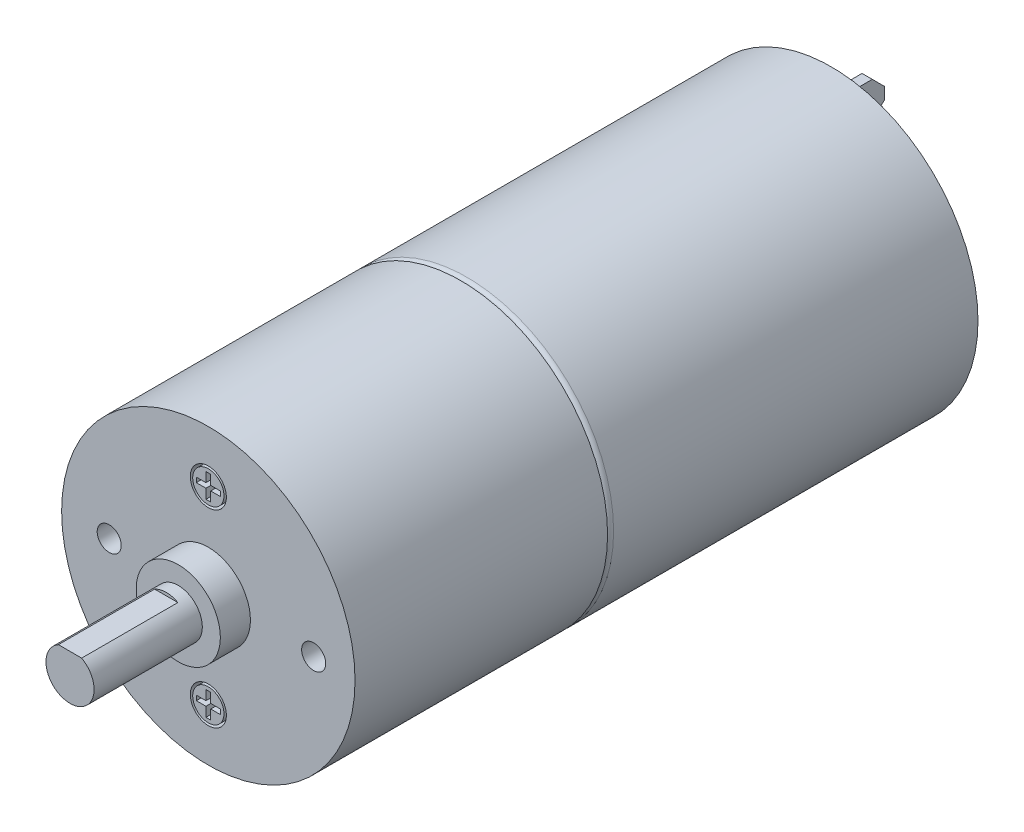
from build123d import *

# Parameters (mm, degrees)
IZIM1_R                     = 12.2
Y_KSEKLIK_EKSTR_ZYON1_DEPTH = 30.8
RADYUS1_R                   = 0.5
IZIM2_R                     = 12.2
Y_KSEKLIK_EKSTR_ZYON2_DEPTH = 21
IZIM3_R                     = 3.5
Y_KSEKLIK_EKSTR_ZYON3_DEPTH = 2.5
IZIM4_R                     = 2
Y_KSEKLIK_EKSTR_ZYON4_DEPTH = 9
IZIM5_R                     = 1
KES_EKSTR_ZYON1_DEPTH       = 10
IZIM6_R                     = 1.5
IZIM6_R_2                   = 1.3
KES_EKSTR_ZYON2_DEPTH       = 1
KES_EKSTR_ZYON3_DEPTH       = 8
IZIM9_R                     = 3.25
Y_KSEKLIK_EKSTR_ZYON5_DEPTH = 1
IZIM10_R                    = 0.75
Y_KSEKLIK_EKSTR_ZYON6_DEPTH = 5
IZIM11_W                    = 0.852537123
IZIM11_H                    = 3
Y_KSEKLIK_EKSTR_ZYON7_DEPTH = 4
IZIM12_R                    = 0.75
KES_EKSTR_ZYON4_DEPTH       = 4
PAH1_SIZE                   = 1


with BuildPart() as part:
    # izim1 → Y_kseklik-Ekstr_zyon1 (new body)
    with BuildSketch(Plane.XY):
        with Locations(Location((-41.143471688, 10.161406423, 0), (0, 0, 180))):
            Circle(IZIM1_R)
    extrude(amount=Y_KSEKLIK_EKSTR_ZYON1_DEPTH)

    # Radyus1
    radyus1_edges = [part.edges().sort_by_distance(p)[0] for p in [
        (-28.943471688, 10.161406423, 30.8),
    ]]
    fillet(radyus1_edges, radius=RADYUS1_R)

    # izim2 → Y_kseklik-Ekstr_zyon2 (add)
    with BuildSketch(Plane.XY.offset(30.8)):
        with Locations(Location((-41.143471688, 10.161406423, 0), (0, 0, 180))):
            Circle(IZIM2_R)
    extrude(amount=Y_KSEKLIK_EKSTR_ZYON2_DEPTH)

    # izim3 → Y_kseklik-Ekstr_zyon3 (add)
    with BuildSketch(Plane.XY.offset(51.8)):
        with Locations((-41.143471688, 10.161406423)):
            Circle(IZIM3_R)
    extrude(amount=Y_KSEKLIK_EKSTR_ZYON3_DEPTH)

    # izim4 → Y_kseklik-Ekstr_zyon4 (add)
    with BuildSketch(Plane.XY.offset(54.3)):
        with Locations((-41.143471688, 10.161406423)):
            Circle(IZIM4_R)
    extrude(amount=Y_KSEKLIK_EKSTR_ZYON4_DEPTH)

    # izim5 → Kes-Ekstr_zyon1 (cut)
    with BuildSketch(Plane.XY.offset(51.8)):
        with Locations((-49.384663885, 10.161406423)):
            Circle(IZIM5_R)
        with Locations((-32.384663885, 10.161406423)):
            Circle(IZIM5_R)
    extrude(amount=-KES_EKSTR_ZYON1_DEPTH, mode=Mode.SUBTRACT)

    # izim6 → Kes-Ekstr_zyon2 (cut)
    with BuildSketch(Plane.XY.offset(51.8)):
        with Locations((-41.143471688, 2.311406423)):
            Circle(IZIM6_R)
        with Locations((-41.143471688, 2.311406423)):
            Circle(IZIM6_R_2, mode=Mode.SUBTRACT)
        Polygon((-40.943471688, 1.311406423), (-40.943471688, 2.111406423), (-40.143471688, 2.111406423), (-40.143471688, 2.511406423), (-40.943471688, 2.511406423), (-40.943471688, 3.311406423), (-41.343471688, 3.311406423), (-41.343471688, 2.511406423), (-42.143471688, 2.511406423), (-42.143471688, 2.111406423), (-41.343471688, 2.111406423), (-41.343471688, 1.311406423), align=None)
        with Locations((-41.143471688, 18.011406423)):
            Circle(IZIM6_R)
        with Locations((-41.143471688, 18.011406423)):
            Circle(IZIM6_R_2, mode=Mode.SUBTRACT)
        Polygon((-41.343471688, 19.011406423), (-41.343471688, 18.211406423), (-42.143471688, 18.211406423), (-42.143471688, 17.811406423), (-41.343471688, 17.811406423), (-41.343471688, 17.011406423), (-40.943471688, 17.011406423), (-40.943471688, 17.811406423), (-40.143471688, 17.811406423), (-40.143471688, 18.211406423), (-40.943471688, 18.211406423), (-40.943471688, 19.011406423), align=None)
    extrude(amount=-KES_EKSTR_ZYON2_DEPTH, mode=Mode.SUBTRACT)

    # izim8 → Kes-Ekstr_zyon3 (cut)
    with BuildSketch(Plane.XY.offset(63.3)):
        with BuildLine():
            Line((-42.111717524, 11.911406423), (-40.175225851, 11.911406423))
            ThreePointArc((-40.175225851, 11.911406423), (-41.143471688, 12.161406423), (-42.111717524, 11.911406423))
        make_face()
    extrude(amount=-KES_EKSTR_ZYON3_DEPTH, mode=Mode.SUBTRACT)

    # izim9 → Y_kseklik-Ekstr_zyon5 (add)
    with BuildSketch(Plane(origin=(0, 0, 0), x_dir=(-1, 0, 0), z_dir=(0, 0, -1))):
        with Locations(Location((41.143471688, 10.161406423, 0), (0, 0, 180))):
            Circle(IZIM9_R)
    extrude(amount=Y_KSEKLIK_EKSTR_ZYON5_DEPTH)

    # izim10 → Y_kseklik-Ekstr_zyon6 (add)
    with BuildSketch(Plane(origin=(0, 0, -1), x_dir=(-1, 0, 0), z_dir=(0, 0, -1))):
        with Locations((41.143471688, 10.161406423)):
            Circle(IZIM10_R)
    extrude(amount=Y_KSEKLIK_EKSTR_ZYON6_DEPTH)

    # izim11 → Y_kseklik-Ekstr_zyon7 (add)
    with BuildSketch(Plane(origin=(0, 0, 0), x_dir=(-1, 0, 0), z_dir=(0, 0, -1))):
        with Locations((41.159259413, 18.661406423)):
            Rectangle(IZIM11_W, IZIM11_H)
        with Locations((41.159259413, 1.661406423)):
            Rectangle(IZIM11_W, IZIM11_H)
    extrude(amount=Y_KSEKLIK_EKSTR_ZYON7_DEPTH)

    # izim12 → Kes-Ekstr_zyon4 (cut)
    with BuildSketch(Plane(origin=(-40.732990851, 0, 0), x_dir=(0, 0, -1), z_dir=(1, 0, 0))):
        with Locations((1.925401768, 18.661406423)):
            Circle(IZIM12_R)
        with Locations((1.925401768, 1.661406423)):
            Circle(IZIM12_R)
    extrude(amount=-KES_EKSTR_ZYON4_DEPTH, mode=Mode.SUBTRACT)

    # Pah1
    pah1_edges = [part.edges().sort_by_distance(p)[0] for p in [
        (-41.159259412, 17.161406423, -4),
        (-41.159259412, 20.161406423, -4),
        (-41.159259412, 0.161406423, -4),
        (-41.159259412, 3.161406423, -4),
    ]]
    chamfer(pah1_edges, length=PAH1_SIZE)


solid = part.part
